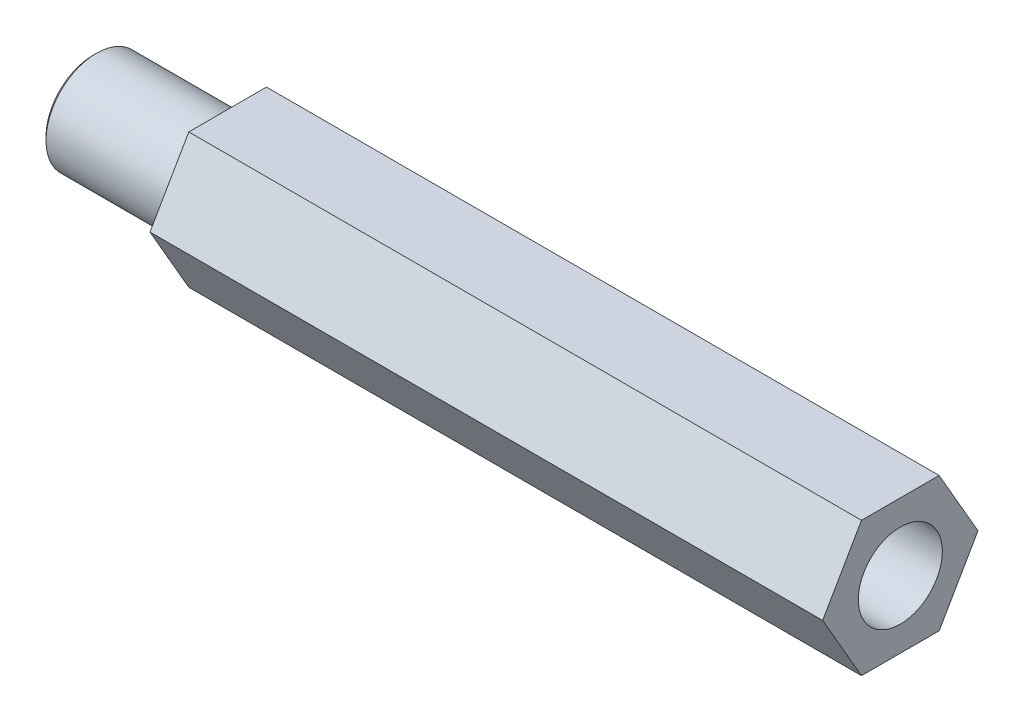
from build123d import *

# Parameters (mm, degrees)
EXTRUDE_1_DEPTH     = 40
SKETCH_2_R          = 2.5
CUT_EXTRUDE_1_DEPTH = 12
SKETCH_3_R          = 3
EXTRUDE_2_DEPTH     = 8
CHAMFER_1_SIZE      = 0.2


with BuildPart() as part:
    # 草图1 → 凸台-拉伸1 (new body)
    with BuildSketch(Plane(origin=(0, 0, 0), x_dir=(0, 0, -1), z_dir=(1, 0, 0))):
        Polygon((4.618802154, 0), (2.309401077, 4), (-2.309401077, 4), (-4.618802154, 0), (-2.309401077, -4), (2.309401077, -4), align=None)
    extrude(amount=EXTRUDE_1_DEPTH)

    # 草图2 → 切除-拉伸1 (cut)
    with BuildSketch(Plane(origin=(40, 0, 0), x_dir=(0, 0, -1), z_dir=(1, 0, 0))):
        Circle(SKETCH_2_R)
    extrude(amount=-CUT_EXTRUDE_1_DEPTH, mode=Mode.SUBTRACT)

    # 草图3 → 凸台-拉伸2 (add)
    with BuildSketch(Plane.ZY):
        Circle(SKETCH_3_R)
    extrude(amount=EXTRUDE_2_DEPTH)

    # 倒角1
    chamfer_1_edges = [part.edges().sort_by_distance(p)[0] for p in [
        (-8, 0, -3),
    ]]
    chamfer(chamfer_1_edges, length=CHAMFER_1_SIZE)


solid = part.part
